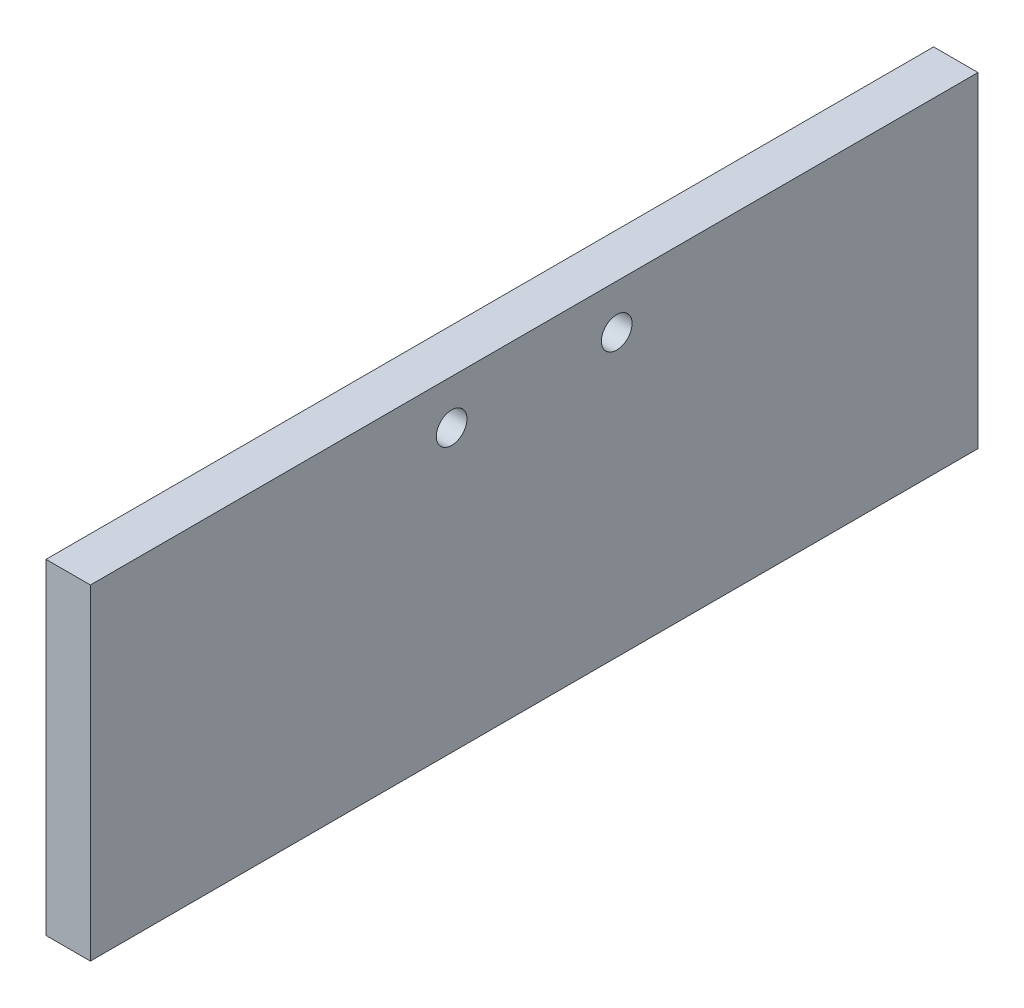
from build123d import *

# Parameters (mm, degrees)
SKETCH1_W           = 127
SKETCH1_H           = 12.7
SKETCH1_R           = 2.1971
SKETCH1_H_2         = 33.909
BOSS_EXTRUDE1_DEPTH = 6.35


with BuildPart() as part:
    # Sketch1 → Boss-Extrude1 (new body)
    with BuildSketch(Plane(origin=(0, 0, 0), x_dir=(0, 0, -1), z_dir=(1, 0, 0))):
        Rectangle(SKETCH1_W, SKETCH1_H)
        with Locations((11.811, 0)):
            Circle(SKETCH1_R, mode=Mode.SUBTRACT)
        with Locations((-11.811, 0)):
            Circle(SKETCH1_R, mode=Mode.SUBTRACT)
        with Locations((0, -23.3045)):
            Rectangle(SKETCH1_W, SKETCH1_H_2)
    extrude(amount=BOSS_EXTRUDE1_DEPTH)


solid = part.part
